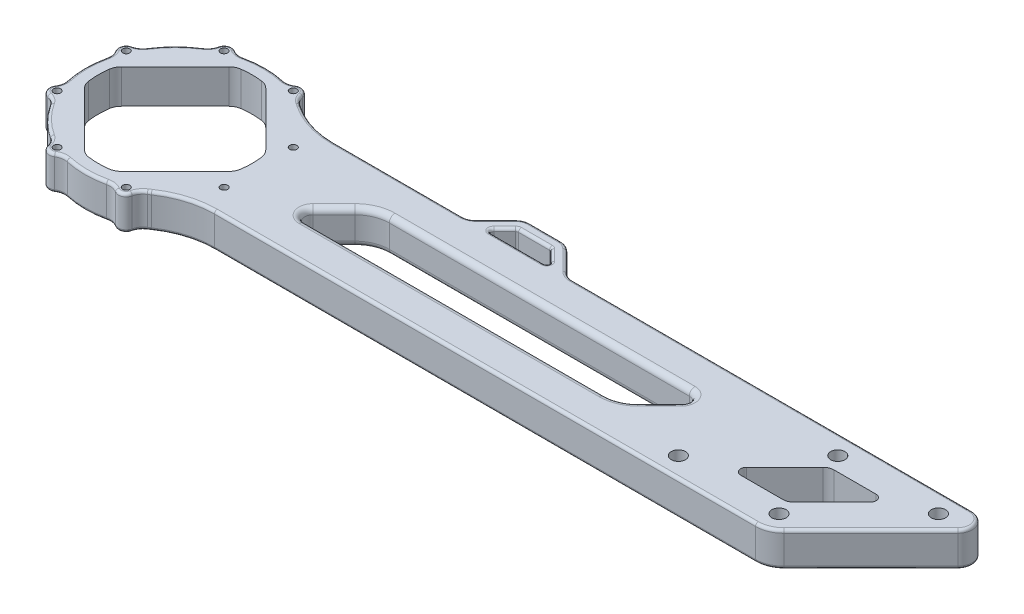
from build123d import *

# Parameters (mm, degrees)
SKETCH_1_R               = 1.25
EXTRUDE_1_DEPTH          = 12
SKETCH_2_R               = 1.25
EXTRUDE_2_DEPTH          = 12
FILLET_1_R               = 30
EXTRUDE_3_DEPTH          = 12
CUT_EXTRUDE_1_DEPTH      = 1
CUT_EXTRUDE_1_DEPTH_BACK = 13
SKETCH_5_R               = 2.5
CUT_EXTRUDE_2_DEPTH      = 1
CUT_EXTRUDE_2_DEPTH_BACK = 13
CUT_EXTRUDE_3_DEPTH      = 13
FILLET_2_R               = 1
FILLET_3_R               = 2


with BuildPart() as part:
    # 草图1 → 凸台-拉伸1 (new body)
    with BuildSketch(Plane(origin=(0, 0, 0), x_dir=(1, 0, 0), z_dir=(0, 1, 0))):
        with BuildLine():
            ThreePointArc((-14.834767347, -29.929491072), (-13.202578417, -31.873843872), (-10.673581506, -31.653110683))
            ThreePointArc((-10.673581506, -31.653110683), (-8.853668896, -30.946539181), (-6.901907846, -30.990743265))
            ThreePointArc((-6.901907846, -30.990743265), (0, -31.75), (6.901907846, -30.990743265))
            ThreePointArc((6.901907846, -30.990743265), (8.853668896, -30.946539181), (10.673581506, -31.653110683))
            ThreePointArc((10.673581506, -31.653110683), (13.202578417, -31.873843872), (14.834767347, -29.929491072))
            ThreePointArc((14.834767347, -29.929491072), (15.622018395, -28.142997024), (17.033378876, -26.794150557))
            ThreePointArc((17.033378876, -26.794150557), (22.450640303, -22.450640303), (26.794150557, -17.033378876))
            ThreePointArc((26.794150557, -17.033378876), (28.142997024, -15.622018395), (29.929491072, -14.834767347))
            ThreePointArc((29.929491072, -14.834767347), (31.873843872, -13.202578417), (31.653110683, -10.673581506))
            ThreePointArc((31.653110683, -10.673581506), (30.946539181, -8.853668896), (30.990743265, -6.901907846))
            ThreePointArc((30.990743265, -6.901907846), (31.75, 0), (30.990743265, 6.901907846))
            ThreePointArc((30.990743265, 6.901907846), (30.946539181, 8.853668896), (31.653110683, 10.673581506))
            ThreePointArc((31.653110683, 10.673581506), (31.873843872, 13.202578417), (29.929491072, 14.834767347))
            ThreePointArc((29.929491072, 14.834767347), (28.142997024, 15.622018395), (26.794150557, 17.033378876))
            ThreePointArc((26.794150557, 17.033378876), (22.450640303, 22.450640303), (17.033378876, 26.794150557))
            ThreePointArc((17.033378876, 26.794150557), (15.622018395, 28.142997024), (14.834767347, 29.929491072))
            ThreePointArc((14.834767347, 29.929491072), (13.202578417, 31.873843872), (10.673581506, 31.653110683))
            ThreePointArc((10.673581506, 31.653110683), (8.853668896, 30.946539181), (6.901907846, 30.990743265))
            ThreePointArc((6.901907846, 30.990743265), (0, 31.75), (-6.901907846, 30.990743265))
            ThreePointArc((-6.901907846, 30.990743265), (-8.853668896, 30.946539181), (-10.673581506, 31.653110683))
            ThreePointArc((-10.673581506, 31.653110683), (-13.202578417, 31.873843872), (-14.834767347, 29.929491072))
            ThreePointArc((-14.834767347, 29.929491072), (-15.622018395, 28.142997024), (-17.033378876, 26.794150557))
            ThreePointArc((-17.033378876, 26.794150557), (-22.450640303, 22.450640303), (-26.794150557, 17.033378876))
            ThreePointArc((-26.794150557, 17.033378876), (-28.142997024, 15.622018395), (-29.929491072, 14.834767347))
            ThreePointArc((-29.929491072, 14.834767347), (-31.873843872, 13.202578417), (-31.653110683, 10.673581506))
            ThreePointArc((-31.653110683, 10.673581506), (-30.946539181, 8.853668896), (-30.990743265, 6.901907846))
            ThreePointArc((-30.990743265, 6.901907846), (-31.75, 0), (-30.990743265, -6.901907846))
            ThreePointArc((-30.990743265, -6.901907846), (-30.946539181, -8.853668896), (-31.653110683, -10.673581506))
            ThreePointArc((-31.653110683, -10.673581506), (-31.873843872, -13.202578417), (-29.929491072, -14.834767347))
            ThreePointArc((-29.929491072, -14.834767347), (-28.142997024, -15.622018395), (-26.794150557, -17.033378876))
            ThreePointArc((-26.794150557, -17.033378876), (-22.450640303, -22.450640303), (-17.033378876, -26.794150557))
            ThreePointArc((-17.033378876, -26.794150557), (-15.622018395, -28.142997024), (-14.834767347, -29.929491072))
        make_face()
        with Locations((-12.150198978, -29.333175157)):
            Circle(SKETCH_1_R, mode=Mode.SUBTRACT)
        with Locations((-29.333175157, -12.150198978)):
            Circle(SKETCH_1_R, mode=Mode.SUBTRACT)
        with Locations((-29.333175157, 12.150198978)):
            Circle(SKETCH_1_R, mode=Mode.SUBTRACT)
        with Locations((-12.150198978, 29.333175157)):
            Circle(SKETCH_1_R, mode=Mode.SUBTRACT)
        with Locations((12.150198978, 29.333175157)):
            Circle(SKETCH_1_R, mode=Mode.SUBTRACT)
        with Locations((29.333175157, 12.150198978)):
            Circle(SKETCH_1_R, mode=Mode.SUBTRACT)
        with Locations((29.333175157, -12.150198978)):
            Circle(SKETCH_1_R, mode=Mode.SUBTRACT)
        with Locations((12.150198978, -29.333175157)):
            Circle(SKETCH_1_R, mode=Mode.SUBTRACT)
        with BuildLine():
            Line((-6.482548759, -25.337256394), (-25.337256394, -6.482548759))
            ThreePointArc((-25.337256394, -6.482548759), (-26.282254342, -5.166211623), (-26.756659417, -3.616790956))
            ThreePointArc((-26.756659417, -3.616790956), (-27, 0), (-26.756659417, 3.616790956))
            ThreePointArc((-26.756659417, 3.616790956), (-26.282254342, 5.166211623), (-25.337256394, 6.482548759))
            Line((-25.337256394, 6.482548759), (-6.482548759, 25.337256394))
            ThreePointArc((-6.482548759, 25.337256394), (-5.166211623, 26.282254342), (-3.616790956, 26.756659417))
            ThreePointArc((-3.616790956, 26.756659417), (0, 27), (3.616790956, 26.756659417))
            ThreePointArc((3.616790956, 26.756659417), (5.166211623, 26.282254342), (6.482548759, 25.337256394))
            Line((6.482548759, 25.337256394), (25.337256394, 6.482548759))
            ThreePointArc((25.337256394, 6.482548759), (26.282254342, 5.166211623), (26.756659417, 3.616790956))
            ThreePointArc((26.756659417, 3.616790956), (27, 0), (26.756659417, -3.616790956))
            ThreePointArc((26.756659417, -3.616790956), (26.282254342, -5.166211623), (25.337256394, -6.482548759))
            Line((25.337256394, -6.482548759), (6.482548759, -25.337256394))
            ThreePointArc((6.482548759, -25.337256394), (5.166211623, -26.282254342), (3.616790956, -26.756659417))
            ThreePointArc((3.616790956, -26.756659417), (0, -27), (-3.616790956, -26.756659417))
            ThreePointArc((-3.616790956, -26.756659417), (-5.166211623, -26.282254342), (-6.482548759, -25.337256394))
        make_face(mode=Mode.SUBTRACT)
    extrude(amount=EXTRUDE_1_DEPTH)

    # 草图2 → 凸台-拉伸2 (add)
    with BuildSketch(Plane.XZ):
        with BuildLine():
            Line((23.81307414, 21), (224.857864376, 21))
            ThreePointArc((224.857864376, 21), (228.6846987, 20.238795325), (231.928932188, 18.071067812))
            Line((231.928932188, 18.071067812), (262.464466094, -12.464466094))
            ThreePointArc((262.464466094, -12.464466094), (263.548329851, -17.913417162), (258.928932188, -21))
            Line((258.928932188, -21), (229, -21))
            Line((229, -21), (23.81307414, -21))
            ThreePointArc((23.81307414, -21), (29.768985079, 0), (23.81307414, 21))
        make_face()
        with Locations((29.333175157, 12.150198978)):
            Circle(SKETCH_2_R, mode=Mode.SUBTRACT)
        with Locations((29.333175157, -12.150198978)):
            Circle(SKETCH_2_R, mode=Mode.SUBTRACT)
    extrude(amount=-EXTRUDE_2_DEPTH)

    # 圆角1
    fillet_1_edges = [part.edges().sort_by_distance(p)[0] for p in [
        (23.81307414, 6, 21),
        (23.81307414, 6, -21),
    ]]
    fillet(fillet_1_edges, radius=FILLET_1_R)

    # 草图3 → 凸台-拉伸3 (add)
    with BuildSketch(Plane.XZ):
        with BuildLine():
            Line((104.633601005, -30.85), (93.775736629, -30.85))
            ThreePointArc((93.775736629, -30.85), (91.862319467, -30.469397663), (90.240202723, -29.385533906))
            Line((90.240202723, -29.385533906), (83.319134911, -22.464466094))
            ThreePointArc((83.319134911, -22.464466094), (81.697018167, -21.380602337), (79.783601005, -21))
            Line((79.783601005, -21), (76.267097432, -21))
            Line((76.267097432, -21), (76.267097432, -10.473314716))
            Line((76.267097432, -10.473314716), (121.997012892, -10.473314716))
            Line((121.997012892, -10.473314716), (121.997012892, -21))
            Line((121.997012892, -21), (118.625736629, -21))
            ThreePointArc((118.625736629, -21), (116.712319467, -21.380602337), (115.090202723, -22.464466094))
            Line((115.090202723, -22.464466094), (108.169134911, -29.385533906))
            ThreePointArc((108.169134911, -29.385533906), (106.547018167, -30.469397663), (104.633601005, -30.85))
        make_face()
        with BuildLine():
            Line((108.483601005, -21), (89.925736629, -21))
            ThreePointArc((89.925736629, -21), (89.001857096, -21.617316568), (89.218629848, -22.707106781))
            Line((89.218629848, -22.707106781), (93.068629848, -26.557106781))
            ThreePointArc((93.068629848, -26.557106781), (93.393053196, -26.773879533), (93.775736629, -26.85))
            Line((93.775736629, -26.85), (104.633601005, -26.85))
            ThreePointArc((104.633601005, -26.85), (105.016284437, -26.773879533), (105.340707786, -26.557106781))
            Line((105.340707786, -26.557106781), (109.190707786, -22.707106781))
            ThreePointArc((109.190707786, -22.707106781), (109.407480538, -21.617316568), (108.483601005, -21))
        make_face(mode=Mode.SUBTRACT)
    extrude(amount=-EXTRUDE_3_DEPTH)

    # 草图4 → 切除-拉伸1 (cut, two sides)
    with BuildSketch(Plane(origin=(0, 12, 0), x_dir=(1, 0, 0), z_dir=(0, 1, 0))) as cut_extrude_1_sk:
        with BuildLine():
            Line((222.372583002, -9), (207.644660941, -9))
            ThreePointArc((207.644660941, -9), (205.796901876, -7.765366865), (206.230447378, -5.585786438))
            Line((206.230447378, -5.585786438), (219.644660941, 7.828427125))
            ThreePointArc((219.644660941, 7.828427125), (220.942354336, 8.69551813), (222.473088065, 9))
            Line((222.473088065, 9), (237.201010127, 9))
            ThreePointArc((237.201010127, 9), (239.048769192, 7.765366865), (238.615223689, 5.585786438))
            Line((238.615223689, 5.585786438), (225.201010127, -7.828427125))
            ThreePointArc((225.201010127, -7.828427125), (223.903316731, -8.69551813), (222.372583002, -9))
        make_face()
    extrude(amount=CUT_EXTRUDE_1_DEPTH, mode=Mode.SUBTRACT)
    extrude(cut_extrude_1_sk.sketch, amount=-CUT_EXTRUDE_1_DEPTH_BACK, mode=Mode.SUBTRACT)

    # 草图5 → 切除-拉伸2 (cut, two sides)
    with BuildSketch(Plane.XZ) as cut_extrude_2_sk:
        with Locations((254.100505063, -14)):
            Circle(SKETCH_5_R)
        with Locations((218.745166004, -14)):
            Circle(SKETCH_5_R)
        with Locations((226.100505063, 14)):
            Circle(SKETCH_5_R)
        with Locations((190.745166004, 14)):
            Circle(SKETCH_5_R)
    extrude(amount=CUT_EXTRUDE_2_DEPTH, mode=Mode.SUBTRACT)
    extrude(cut_extrude_2_sk.sketch, amount=-CUT_EXTRUDE_2_DEPTH_BACK, mode=Mode.SUBTRACT)

    # 草图6 → 切除-拉伸3 (cut, through all)
    with BuildSketch(Plane.XZ):
        with BuildLine():
            Line((174.728248539, -2.878679656), (167.364287508, 4.485281374))
            ThreePointArc((167.364287508, 4.485281374), (163.471207322, 7.08655439), (158.879006134, 8))
            Line((158.879006134, 8), (53.482011793, 8))
            ThreePointArc((53.482011793, 8), (50.710373196, 6.148050297), (51.36069145, 2.878679656))
            Line((51.36069145, 2.878679656), (58.72465248, -4.485281374))
            ThreePointArc((58.72465248, -4.485281374), (62.617732666, -7.08655439), (67.209933855, -8))
            Line((67.209933855, -8), (172.606928195, -8))
            ThreePointArc((172.606928195, -8), (175.378566793, -6.148050297), (174.728248539, -2.878679656))
        make_face()
    extrude(amount=-CUT_EXTRUDE_3_DEPTH, mode=Mode.SUBTRACT)

    # 圆角2
    fillet_2_edges = [part.edges().sort_by_distance(p)[0] for p in [
        (-30.946539181, 12, -8.853668896),
        (-31.75, 12, 0),
        (-30.946539181, 12, 8.853668896),
        (-31.873843872, 12, 13.202578417),
        (-28.142997024, 12, 15.622018395),
        (-22.450640303, 12, 22.450640303),
        (-15.622018395, 12, 28.142997024),
        (-13.202578417, 12, 31.873843872),
        (8.853668896, 12, 30.946539181),
        (13.202578417, 12, 31.873843872),
        (129.836276184, 0, 21),
        (263.548329851, 0, -17.913417162),
        (247.196699141, 0, 2.803300859),
        (228.6846987, 0, 20.238795325),
        (228.6846987, 12, 20.238795325),
        (247.196699141, 12, 2.803300859),
        (263.548329851, 12, -17.913417162),
        (188.777334408, 12, -21),
        (17.469361222, 12, -26.511958028),
        (17.469361222, 0, -26.511958028),
        (57.299144499, 0, -21),
        (129.836276184, 12, 21),
        (25.963694773, 0, -22.335389083),
        (25.963694773, 12, -22.335389083),
        (25.963694773, 0, 22.335389083),
        (25.963694773, 12, 22.335389083),
        (15.622018395, 12, 28.142997024),
        (99.204668817, 0, -21),
        (188.777334408, 0, -21),
        (99.204668817, 12, -21),
        (57.299144499, 12, -21),
        (89.001857096, 12, -21.617316568),
        (89.001857096, 0, -21.617316568),
        (105.016284437, 12, -26.773879533),
        (105.016284437, 0, -26.773879533),
        (107.265707786, 12, -24.632106781),
        (107.265707786, 0, -24.632106781),
        (99.204668817, 12, -30.85),
        (99.204668817, 0, -30.85),
        (91.862319467, 12, -30.469397663),
        (91.862319467, 0, -30.469397663),
        (86.779668817, 12, -25.925),
        (86.779668817, 0, -25.925),
        (81.697018167, 12, -21.380602337),
        (81.697018167, 0, -21.380602337),
        (116.712319467, 0, -21.380602337),
        (109.407480538, 0, -21.617316568),
        (99.204668817, 0, -26.85),
        (93.393053196, 0, -26.773879533),
        (91.143629848, 0, -24.632106781),
        (106.547018167, 0, -30.469397663),
        (111.629668817, 0, -25.925),
        (116.712319467, 12, -21.380602337),
        (111.629668817, 12, -25.925),
        (106.547018167, 12, -30.469397663),
        (91.143629848, 12, -24.632106781),
        (93.393053196, 12, -26.773879533),
        (99.204668817, 12, -26.85),
        (109.407480538, 12, -21.617316568),
        (17.469361222, 12, 26.511958028),
        (-13.202578417, 0, 31.873843872),
        (-15.622018395, 0, 28.142997024),
        (-22.450640303, 0, 22.450640303),
        (-28.142997024, 0, 15.622018395),
        (-31.873843872, 0, 13.202578417),
        (-30.946539181, 0, 8.853668896),
        (-31.75, 0, 0),
        (-30.946539181, 0, -8.853668896),
        (-31.873843872, 0, -13.202578417),
        (-28.142997024, 0, -15.622018395),
        (-22.450640303, 0, -22.450640303),
        (-15.622018395, 0, -28.142997024),
        (-13.202578417, 0, -31.873843872),
        (-8.853668896, 0, -30.946539181),
        (0, 0, -31.75),
        (8.853668896, 0, -30.946539181),
        (13.202578417, 0, -31.873843872),
        (15.622018395, 0, -28.142997024),
        (17.469361222, 0, 26.511958028),
        (15.622018395, 0, 28.142997024),
        (13.202578417, 0, 31.873843872),
        (8.853668896, 0, 30.946539181),
        (0, 0, 31.75),
        (-8.853668896, 0, 30.946539181),
        (-8.853668896, 12, 30.946539181),
        (15.622018395, 12, -28.142997024),
        (13.202578417, 12, -31.873843872),
        (8.853668896, 12, -30.946539181),
        (0, 12, -31.75),
        (-8.853668896, 12, -30.946539181),
        (-13.202578417, 12, -31.873843872),
        (-15.622018395, 12, -28.142997024),
        (-22.450640303, 12, -22.450640303),
        (0, 12, 31.75),
        (-28.142997024, 12, -15.622018395),
        (-31.873843872, 12, -13.202578417),
    ]]
    fillet(fillet_2_edges, radius=FILLET_2_R)

    # 圆角3
    fillet_3_edges = [part.edges().sort_by_distance(p)[0] for p in [
        (62.617732666, 12, -7.08655439),
        (55.042671965, 12, -0.803300859),
        (50.710373196, 12, 6.148050297),
        (106.180508964, 12, 8),
        (163.471207322, 12, 7.08655439),
        (171.046268023, 12, 0.803300859),
        (175.378566793, 12, -6.148050297),
        (119.908431025, 12, -8),
        (62.617732666, 0, -7.08655439),
        (119.908431025, 0, -8),
        (175.378566793, 0, -6.148050297),
        (171.046268023, 0, 0.803300859),
        (163.471207322, 0, 7.08655439),
        (106.180508964, 0, 8),
        (50.710373196, 0, 6.148050297),
        (55.042671965, 0, -0.803300859),
    ]]
    fillet(fillet_3_edges, radius=FILLET_3_R)


solid = part.part
